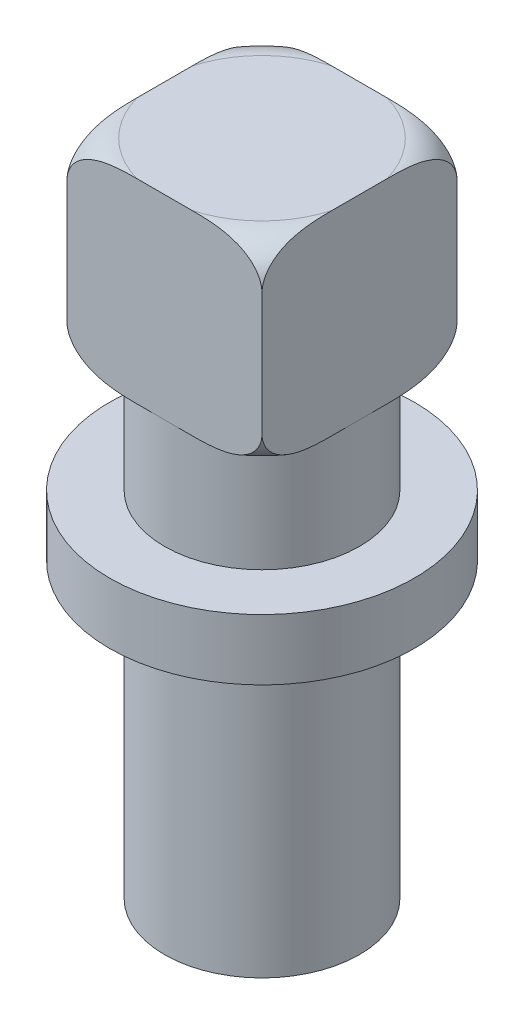
from build123d import *

# Parameters (mm, degrees)
SKETCH2_W           = 16
SKETCH2_H           = 16
BOSS_EXTRUDE1_DEPTH = 16


with BuildPart() as part:
    # Sketch1 → Revolve1 (revolve)
    with BuildSketch(Plane.XY):
        Polygon((0, 0), (8, 0), (8, 24), (12.5, 24), (12.5, 29), (8, 29), (8, 38), (0, 38), align=None)
    revolve(axis=Axis((0, 0, 0), (0, 1, 0)))

    # Sketch2 → Boss-Extrude1 (add)
    with BuildSketch(Plane(origin=(0, 38, 0), x_dir=(1, 0, 0), z_dir=(0, 1, 0))):
        Rectangle(SKETCH2_W, SKETCH2_H)
    extrude(amount=BOSS_EXTRUDE1_DEPTH)

    # Sketch3 → Cut-Revolve1 (revolve, cut)
    with BuildSketch(Plane(origin=(0, 0, 0), x_dir=(0.707106781, 0, -0.707106781), z_dir=(0.707106781, 0, 0.707106781))):
        with BuildLine():
            Line((11.313708499, 54), (8.313708499, 54))
            ThreePointArc((8.313708499, 54), (10.435028843, 53.121320344), (11.313708499, 51))
            Line((11.313708499, 51), (11.313708499, 54))
        make_face()
        with BuildLine():
            Line((11.313708499, 38), (8.313708499, 38))
            ThreePointArc((8.313708499, 38), (10.435028843, 38.878679656), (11.313708499, 41))
            Line((11.313708499, 41), (11.313708499, 38))
        make_face()
    revolve(axis=Axis((0, 34.971130997, 0), (0, -1, 0)), mode=Mode.SUBTRACT)


solid = part.part
